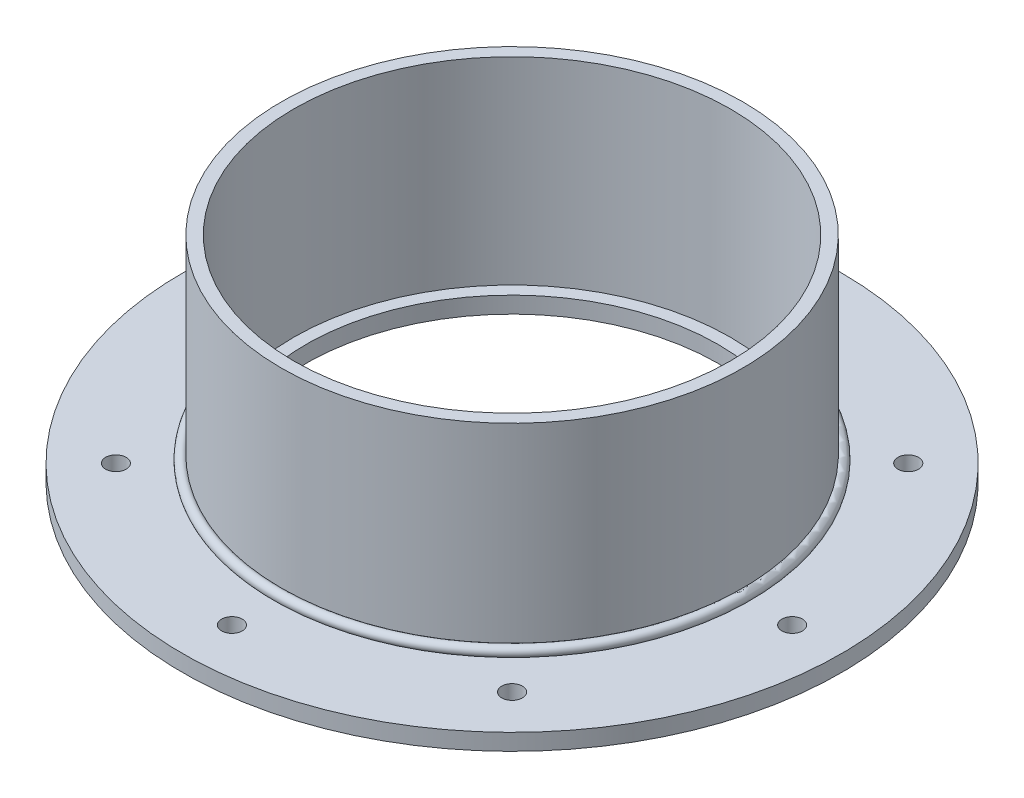
from build123d import *

# Parameters (mm, degrees)
SKETCH1_W          = 47.625
SKETCH1_H          = 6.35
SKETCH2_W          = 4.7625
SKETCH2_H          = 76.2
SKETCH4_R          = 3.96875
CUT_EXTRUDE1_DEPTH = 7.35
CIRPATTERN1_COUNT  = 8


with BuildPart() as part:
    # Sketch1 → Revolve1 (revolve)
    with BuildSketch(Plane.XY, mode=Mode.PRIVATE) as revolve1_sk:
        with Locations((-103.1875, 3.175)):
            Rectangle(SKETCH1_W, SKETCH1_H)
    revolve(revolve1_sk.sketch.rotate(Axis((0, 0, 0), (0, 1, 0)), 270), axis=Axis((0, 0, 0), (0, 1, 0)))  # turned: the seam where the file's is

    # Sketch4 → Cut-Extrude1 (cut, through all)
    with BuildSketch(Plane(origin=(0, 6.35, 0), x_dir=(1, 0, 0), z_dir=(0, 1, 0))):
        with Locations(Location((0, 107.95, 0), (0, 0, 270))):  # turned: the seam where the file's is
            Circle(SKETCH4_R)
    cut_extrude1 = extrude(amount=-CUT_EXTRUDE1_DEPTH, mode=Mode.SUBTRACT)

    # CirPattern1: Cut-Extrude1 ×8 about axis
    cirpattern1_axis = Axis((0, 0, 0), (0, 1, 0))
    for i in range(1, CIRPATTERN1_COUNT):
        add(cut_extrude1.rotate(cirpattern1_axis, i * 360 / CIRPATTERN1_COUNT), mode=Mode.SUBTRACT)


with BuildPart() as body_2:
    # Sketch2 → Revolve2 (revolve)
    with BuildSketch(Plane.XY, mode=Mode.PRIVATE) as revolve2_sk:
        with Locations((-86.51875, 44.45)):
            Rectangle(SKETCH2_W, SKETCH2_H)
    revolve(revolve2_sk.sketch.rotate(Axis((0, 0, 0), (0, 1, 0)), 270), axis=Axis((0, 0, 0), (0, 1, 0)))  # turned: the seam where the file's is


with BuildPart() as body_3:
    # Sketch3 → Revolve3 (revolve)
    with BuildSketch(Plane.XY, mode=Mode.PRIVATE) as revolve3_sk:
        with BuildLine():
            Line((-88.9, 6.35), (-91.685775819, 6.35))
            ThreePointArc((-91.685775819, 6.35), (-91.526537909, 8.976537909), (-88.9, 9.135775819))
            Line((-88.9, 9.135775819), (-88.9, 6.35))
        make_face()
    revolve(revolve3_sk.sketch.rotate(Axis((0, 0, 0), (0, 1, 0)), 270), axis=Axis((0, 0, 0), (0, 1, 0)))  # turned: the seam where the file's is


solid = Compound([part.part, body_2.part, body_3.part])
